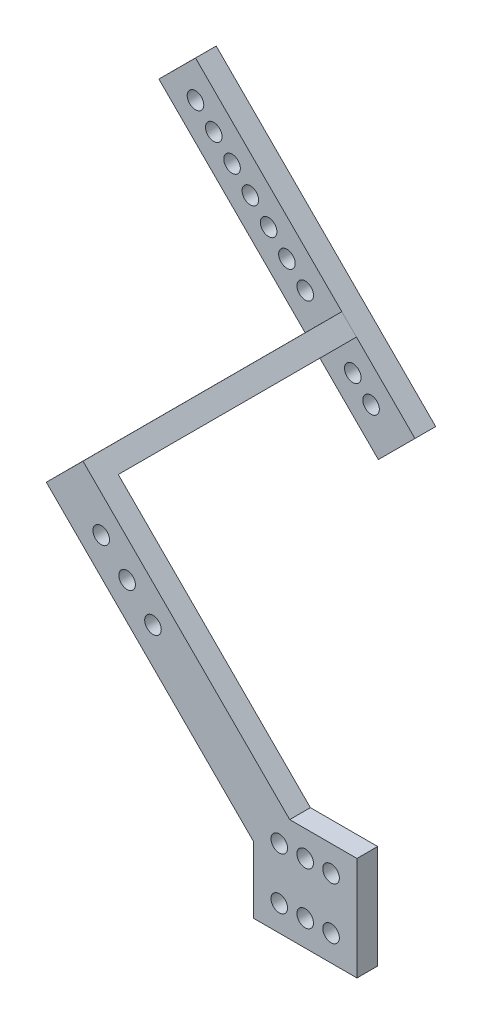
from build123d import *

# Parameters (mm, degrees)
SKETCH_1_W           = 20
SKETCH_1_H           = 20
EXTRUDE_1_DEPTH      = 4
SKETCH_2_R           = 1.6
CUT_EXTRUDE_1_DEPTH  = 4
SKETCH_3_R           = 1.6
CUT_EXTRUDE_2_DEPTH  = 4
EXTRUDE_2_DEPTH      = 50
SKETCH_6_R           = 1.6
CUT_EXTRUDE_3_DEPTH  = 4
SKETCH_7_W           = 10
SKETCH_7_H           = 4
EXTRUDE_3_DEPTH      = 40
EXTRUDE_3_DEPTH_BACK = 20
SKETCH_8_R           = 1.6
CUT_EXTRUDE_4_DEPTH  = 40


with BuildPart() as part:
    # ｽｹｯﾁ1 → ﾎﾞｽ - 押し出し1 (new body)
    with BuildSketch(Plane.XY):
        Polygon((-10.994705775, -41.083316507), (-50.994705775, -1.013434561), (-43.9174693, 6.051459201), (-3.987925088, -33.948540799), align=None)
        with Locations((-0.994705775, -43.948540799)):
            Rectangle(SKETCH_1_W, SKETCH_1_H)
    extrude(amount=EXTRUDE_1_DEPTH)

    # ｽｹｯﾁ2 → ｶｯﾄ - 押し出し1 (cut)
    with BuildSketch(Plane.XY.offset(4)):
        with Locations((-5.994705775, -38.948540799)):
            Circle(SKETCH_2_R)
        with Locations((-0.994705775, -38.948540799)):
            Circle(SKETCH_2_R)
        with Locations((4.005294225, -38.948540799)):
            Circle(SKETCH_2_R)
        with Locations((-0.994705775, -48.948540799)):
            Circle(SKETCH_2_R)
        with Locations((4.005294225, -48.948540799)):
            Circle(SKETCH_2_R)
        with Locations((-5.994705775, -48.948540799)):
            Circle(SKETCH_2_R)
    extrude(amount=-CUT_EXTRUDE_1_DEPTH, mode=Mode.SUBTRACT)

    # ｽｹｯﾁ3 → ｶｯﾄ - 押し出し2 (cut)
    with BuildSketch(Plane.XY.offset(4)):
        with Locations((-40.391193775, -4.558224156)):
            Circle(SKETCH_3_R)
        with Locations((-35.391193775, -9.566959399)):
            Circle(SKETCH_3_R)
        with Locations((-30.391193775, -14.575992494)):
            Circle(SKETCH_3_R)
    extrude(amount=-CUT_EXTRUDE_2_DEPTH, mode=Mode.SUBTRACT)

    # ｽｹｯﾁ4 → ﾎﾞｽ - 押し出し2 (add)
    with BuildSketch(Plane(origin=(0, 0, 0), x_dir=(-1, 0, 0), z_dir=(0, 0, -1))):
        Polygon((43.9174693, 6.051459201), (50.994705775, -1.013434561), (48.168809817, -3.844267497), (41.091536457, 3.220539992), align=None)
    extrude(amount=EXTRUDE_2_DEPTH)

    # ｽｹｯﾁ6 → ｶｯﾄ - 押し出し3 (cut)
    with BuildSketch(Plane(origin=(-24.946130174, 24.989712277, 0), x_dir=(0.707723648, 0.706489376, 0), z_dir=(-0.706489376, 0.707723648, 0))):
        with Locations((-31.806139927, 44)):
            Circle(SKETCH_6_R)
        with Locations((-31.806139927, 37)):
            Circle(SKETCH_6_R)
        with Locations((-31.806139927, 30)):
            Circle(SKETCH_6_R)
        with Locations((-31.806139927, 23)):
            Circle(SKETCH_6_R)
        with Locations((-31.806139927, 16)):
            Circle(SKETCH_6_R)
        with Locations((-31.806139927, 9)):
            Circle(SKETCH_6_R)
        with Locations((-31.806139927, 2)):
            Circle(SKETCH_6_R)
    extrude(amount=-CUT_EXTRUDE_3_DEPTH, mode=Mode.SUBTRACT)

    # ｽｹｯﾁ7 → ﾎﾞｽ - 押し出し3 (add, two sides)
    with BuildSketch(Plane(origin=(-24.946130174, 24.989712277, 0), x_dir=(0.707723648, 0.706489376, 0), z_dir=(-0.706489376, 0.707723648, 0))) as extrude_3_sk:
        with Locations((-31.806139927, 48)):
            Rectangle(SKETCH_7_W, SKETCH_7_H)
    extrude(amount=EXTRUDE_3_DEPTH)
    extrude(extrude_3_sk.sketch, amount=-EXTRUDE_3_DEPTH_BACK)

    # ｽｹｯﾁ8 → ｶｯﾄ - 押し出し4 (cut)
    with BuildSketch(Plane.XY.offset(-46)):
        with Locations((-72.183215705, 27.289339983)):
            Circle(SKETCH_8_R)
        with Locations((-68.650768824, 23.750721746)):
            Circle(SKETCH_8_R)
        with Locations((-65.118321943, 20.212103508)):
            Circle(SKETCH_8_R)
        with Locations((-61.585875062, 16.67348527)):
            Circle(SKETCH_8_R)
        with Locations((-58.053428181, 13.134867033)):
            Circle(SKETCH_8_R)
        with Locations((-54.5209813, 9.596248795)):
            Circle(SKETCH_8_R)
        with Locations((-50.988534419, 6.057630557)):
            Circle(SKETCH_8_R)
        with Locations((-41.804172528, -3.14277686)):
            Circle(SKETCH_8_R)
        with Locations((-38.271725646, -6.681395098)):
            Circle(SKETCH_8_R)
    extrude(amount=-CUT_EXTRUDE_4_DEPTH, mode=Mode.SUBTRACT)


solid = part.part
